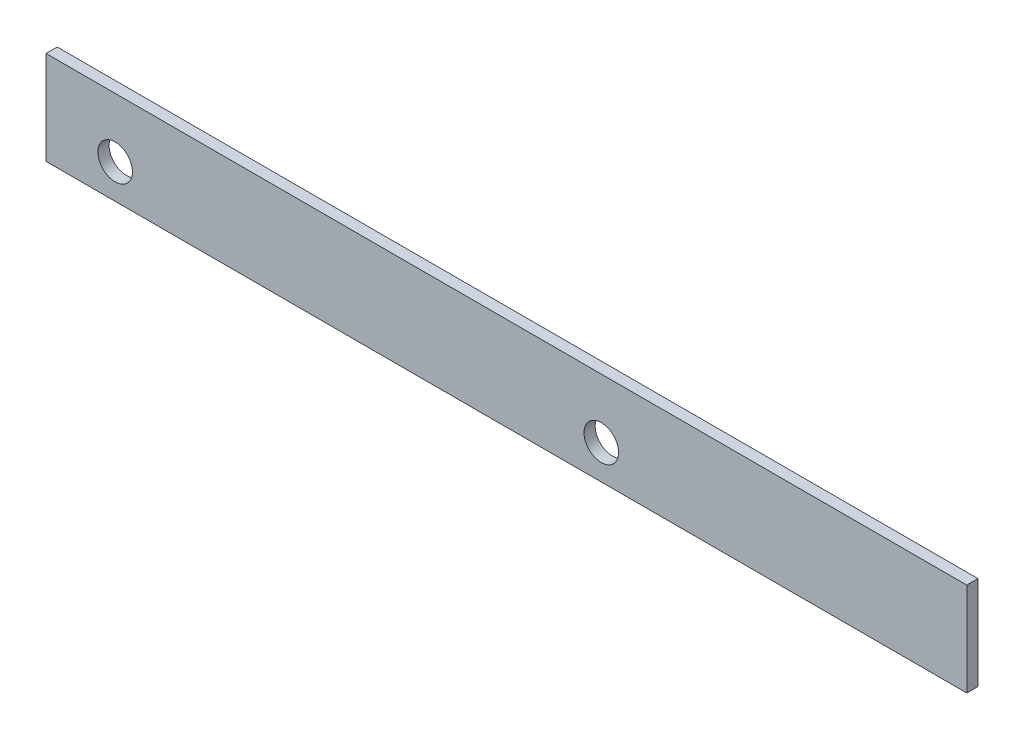
from build123d import *

# Parameters (mm, degrees)
CROQUIS1_W                 = 985
CROQUIS1_H                 = 100
SALIENTE_EXTRUIR1_DEPTH    = 12
CROQUIS2_R                 = 18.5
CORTAR_EXTRUIR1_DEPTH      = 1
CORTAR_EXTRUIR1_DEPTH_BACK = 13
CROQUIS3_R                 = 18.5
CORTAR_EXTRUIR2_DEPTH      = 13


with BuildPart() as part:
    # Croquis1 → Saliente-Extruir1 (new body)
    with BuildSketch(Plane.XY):
        with Locations((492.5, 50)):
            Rectangle(CROQUIS1_W, CROQUIS1_H)
    extrude(amount=SALIENTE_EXTRUIR1_DEPTH)

    # Croquis2 → Cortar-Extruir1 (cut, two sides)
    with BuildSketch(Plane.XY.offset(12)) as cortar_extruir1_sk:
        with Locations((74, 36.5)):
            Circle(CROQUIS2_R)
    extrude(amount=CORTAR_EXTRUIR1_DEPTH, mode=Mode.SUBTRACT)
    extrude(cortar_extruir1_sk.sketch, amount=-CORTAR_EXTRUIR1_DEPTH_BACK, mode=Mode.SUBTRACT)

    # Croquis3 → Cortar-Extruir2 (cut, through all)
    with BuildSketch(Plane.XY.offset(12)):
        with Locations((594, 36.5)):
            Circle(CROQUIS3_R)
    extrude(amount=-CORTAR_EXTRUIR2_DEPTH, mode=Mode.SUBTRACT)


solid = part.part
